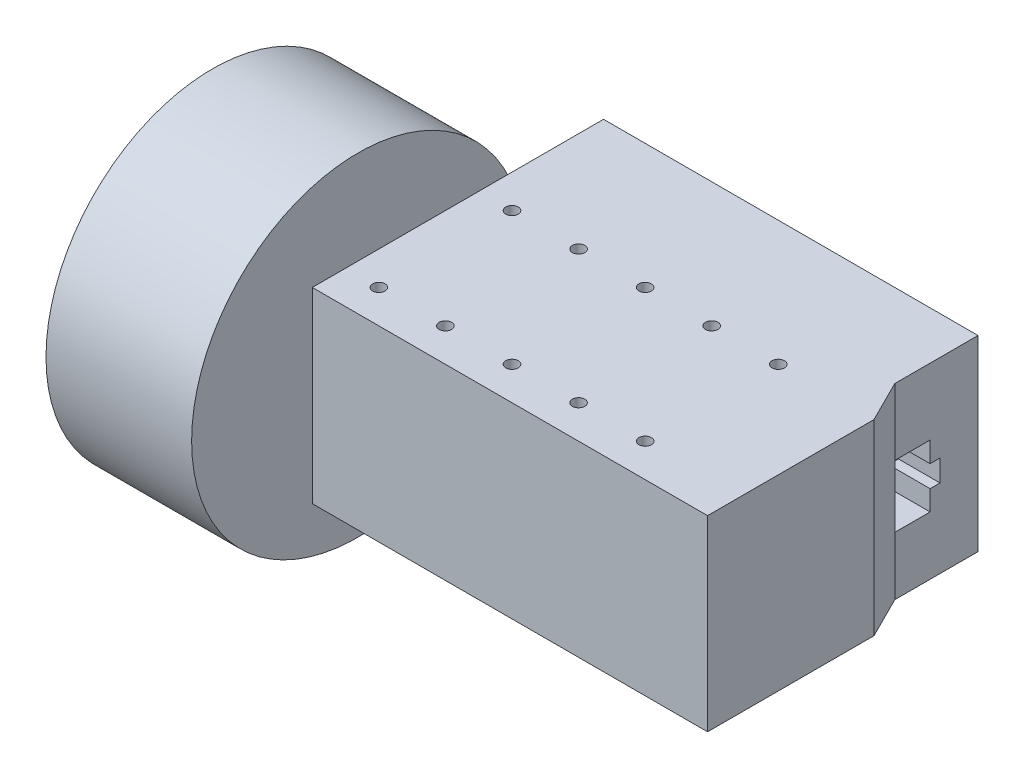
from build123d import *

# Parameters (mm, degrees)
SKETCH_1_R          = 1.5
EXTRUDE_1_DEPTH     = 45
CUT_EXTRUDE_1_DEPTH = 10
SKETCH_3_R          = 3
EXTRUDE_2_DEPTH     = 5
SKETCH_4_R          = 40
EXTRUDE_3_DEPTH     = 35


with BuildPart() as part:
    # 草图1 → 凸台-拉伸1 (new body)
    with BuildSketch(Plane(origin=(0, 0, 0), x_dir=(1, 0, 0), z_dir=(0, 1, 0))):
        Polygon((42.5, 35), (42.5, 15), (47.5, 5), (47.5, -35), (-47.5, -35), (-47.5, 35), align=None)
        with Locations((-39.5, -27)):
            Circle(SKETCH_1_R, mode=Mode.SUBTRACT)
        with Locations((-23.5, -27)):
            Circle(SKETCH_1_R, mode=Mode.SUBTRACT)
        with Locations((-7.5, -27)):
            Circle(SKETCH_1_R, mode=Mode.SUBTRACT)
        with Locations((8.5, -27)):
            Circle(SKETCH_1_R, mode=Mode.SUBTRACT)
        with Locations((24.5, -27)):
            Circle(SKETCH_1_R, mode=Mode.SUBTRACT)
        with Locations((-23.5, 5)):
            Circle(SKETCH_1_R, mode=Mode.SUBTRACT)
        with Locations((-7.5, 5)):
            Circle(SKETCH_1_R, mode=Mode.SUBTRACT)
        with Locations((8.5, 5)):
            Circle(SKETCH_1_R, mode=Mode.SUBTRACT)
        with Locations((24.5, 5)):
            Circle(SKETCH_1_R, mode=Mode.SUBTRACT)
        with Locations((-39.5, 5)):
            Circle(SKETCH_1_R, mode=Mode.SUBTRACT)
    extrude(amount=EXTRUDE_1_DEPTH)

    # 草图2 → 切除-拉伸1 (cut)
    with BuildSketch(Plane(origin=(42.5, 0, 0), x_dir=(0, 0, -1), z_dir=(1, 0, 0))):
        Polygon((15, 29.001286667), (23.488716393, 29.001286667), (23.488716393, 24.069127899), (25.866721513, 24.069127899), (25.866721513, 18.87274634), (23.488716393, 18.87274634), (23.488716393, 14.028661836), (15, 14.028661836), align=None)
    extrude(amount=-CUT_EXTRUDE_1_DEPTH, mode=Mode.SUBTRACT)

    # 草图3 → 凸台-拉伸2 (add)
    with BuildSketch(Plane.ZY.offset(47.5)):
        with Locations((19, 22.5)):
            Circle(SKETCH_3_R)
    extrude(amount=EXTRUDE_2_DEPTH)

    # 草图4 → 凸台-拉伸3 (add)
    with BuildSketch(Plane.ZY.offset(52.5)):
        with Locations((19, 22.5)):
            Circle(SKETCH_4_R)
    extrude(amount=EXTRUDE_3_DEPTH)


solid = part.part
